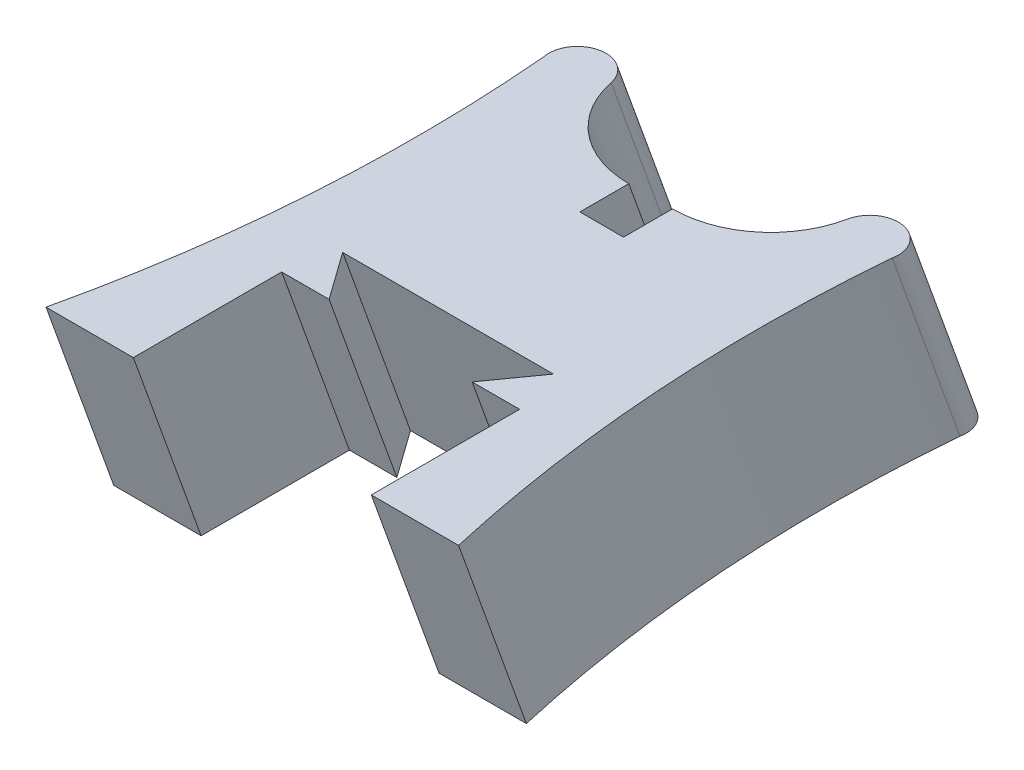
from build123d import *


with BuildPart() as part:
    # Sweep1: sweep along a path in Sketch4
    with BuildLine(Plane(origin=(0, 0, 0), x_dir=(0, 0, -1), z_dir=(1, 0, 0))) as sweep1_path:
        Line((0, 0), (-2.286, 6.35))
    # Sketch2 → Sweep1 (sweep)
    with BuildSketch(Plane(origin=(0, 0, 0), x_dir=(1, 0, 0), z_dir=(0, 1, 0))):
        with BuildLine():
            Line((6.9596, -10.377746103), (4.0132, -10.377746103))
            Line((4.0132, -10.377746103), (4.0132, -5.373946103))
            Line((4.0132, -5.373946103), (2.413, -5.373946103))
            Line((2.413, -5.373946103), (3.556, -3.773746103))
            Line((3.556, -3.773746103), (-3.556, -3.773746103))
            Line((-3.556, -3.773746103), (-2.413, -5.373946103))
            Line((-2.413, -5.373946103), (-4.0132, -5.373946103))
            Line((-4.0132, -5.373946103), (-4.0132, -10.377746103))
            Line((-4.0132, -10.377746103), (-6.9596, -10.377746103))
            ThreePointArc((-6.9596, -10.377746103), (-5.806615649, -2.567356115), (-5.877729648, 5.327357779))
            ThreePointArc((-5.877729648, 5.327357779), (-5.125150102, 6.465638091), (-3.98686979, 5.713058545))
            ThreePointArc((-3.98686979, 5.713058545), (-2.834757288, 3.806705335), (-0.7366, 3.058853897))
            Line((-0.7366, 3.058853897), (-0.7366, 1.407853897))
            Line((-0.7366, 1.407853897), (0.7366, 1.407853897))
            Line((0.7366, 1.407853897), (0.7366, 3.058853897))
            ThreePointArc((0.7366, 3.058853897), (2.834757288, 3.806705335), (3.98686979, 5.713058545))
            ThreePointArc((3.98686979, 5.713058545), (5.125150102, 6.465638091), (5.877729648, 5.327357779))
            ThreePointArc((5.877729648, 5.327357779), (5.806615649, -2.567356115), (6.9596, -10.377746103))
        make_face()
    sweep(path=sweep1_path.line)


solid = part.part
